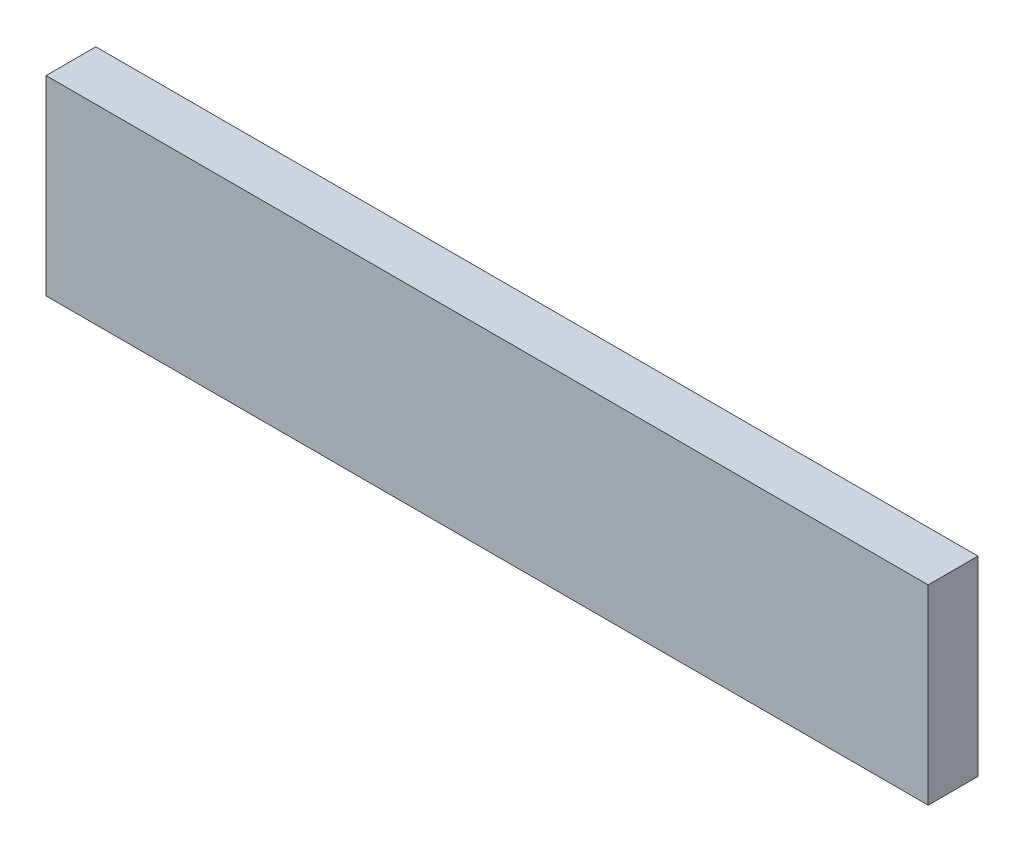
from build123d import *

# Parameters (mm, degrees)
SKETCH1_W           = 177.039638226
SKETCH1_H           = 38.292622135
BOSS_EXTRUDE1_DEPTH = 10


with BuildPart() as part:
    # Sketch1 → Boss-Extrude1 (new body)
    with BuildSketch(Plane.XY):
        with Locations((88.519819113, 19.146311068)):
            Rectangle(SKETCH1_W, SKETCH1_H)
    extrude(amount=BOSS_EXTRUDE1_DEPTH)


solid = part.part
